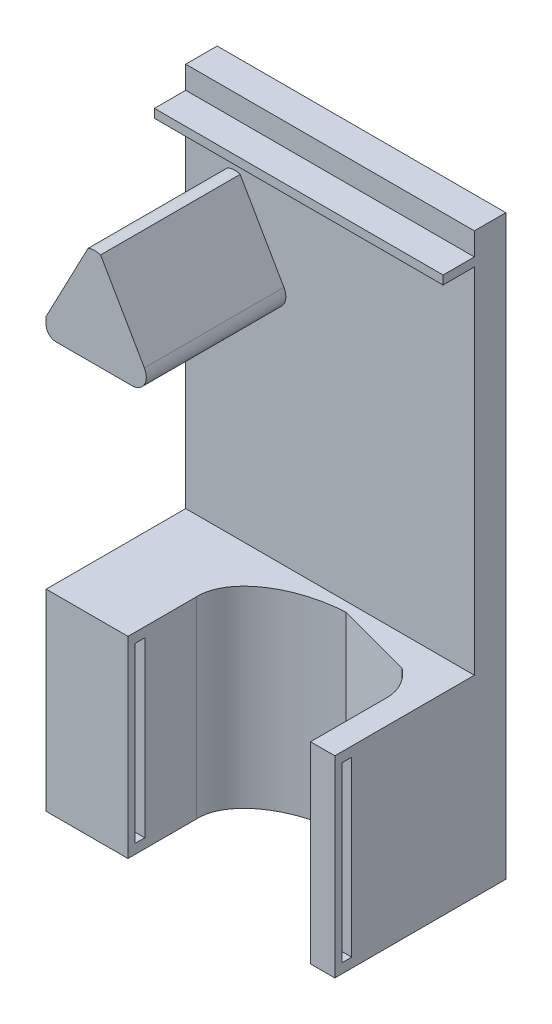
from build123d import *

# Parameters (mm, degrees)
SKETCH1_W           = 60
SKETCH1_H           = 120
BOSS_EXTRUDE1_DEPTH = 6.54
SKETCH17_W          = 60
SKETCH17_H          = 40
BOSS_EXTRUDE6_DEPTH = 29
CUT_EXTRUDE1_REACH  = 42
CUT_EXTRUDE2_REACH  = 37.54
SKETCH21_W          = 37.9445377
SKETCH21_H          = 40
SKETCH23_W          = 2
SKETCH23_H          = 36
CUT_EXTRUDE3_DEPTH  = 9
SKETCH24_W          = 2
SKETCH24_H          = 36
CUT_EXTRUDE4_DEPTH  = 9
BOSS_EXTRUDE8_DEPTH = 29
SKETCH36_W          = 60
SKETCH36_H          = 1.8
BOSS_EXTRUDE9_DEPTH = 6.5
FILLET1_R           = 3
FILLET2_R           = 2


with BuildPart() as part:
    # Sketch1 → Boss-Extrude1 (new body)
    with BuildSketch(Plane.XY):
        Rectangle(SKETCH1_W, SKETCH1_H)
    extrude(amount=BOSS_EXTRUDE1_DEPTH)

    # Sketch17 → Boss-Extrude6 (add)
    with BuildSketch(Plane.XY.offset(6.54)):
        with Locations((0, -40)):
            Rectangle(SKETCH17_W, SKETCH17_H)
    extrude(amount=BOSS_EXTRUDE6_DEPTH)

    # Sketch18 → Cut-Extrude1 (cut, up to next)
    with BuildSketch(Plane(origin=(0, -20, 0), x_dir=(1, 0, 0), z_dir=(0, 1, 0)), mode=Mode.PRIVATE) as cut_extrude1_sk1:
        with BuildLine():
            Line((5.334966353, -8.526396136), (21.291300905, -12.825812438))
            add(Edge.make_bspline(
                [(5.334966353, -8.526396136), (-17.854714365, -9.780670981), (-12.49786254, -23.648890313), (-7.141010715, -37.517109645), (13.926544327, -30.768916863), (34.994099369, -24.020724082), (21.291300905, -12.825812438)],
                knots=[1.570796327, 1.570796327, 1.570796327, 3.340987112, 3.340987112, 5.111177898, 5.111177898, 6.881368684, 6.881368684, 6.881368684], degree=2, weights=[1, 0.633215673, 1, 0.633215673, 1, 0.633215673, 1]))
        make_face()
    cut_extrude1_tool1 = extrude(cut_extrude1_sk1.sketch, amount=-CUT_EXTRUDE1_REACH, mode=Mode.PRIVATE) & part.part
    add(cut_extrude1_tool1.solids().sort_by_distance((5.792514, -20, 20.554542))[0], mode=Mode.SUBTRACT)

    # Sketch21 → Cut-Extrude2 (cut, up to next)
    with BuildSketch(Plane.XY.offset(35.54), mode=Mode.PRIVATE) as cut_extrude2_sk1:
        with Locations((5.97226885, -40)):
            Rectangle(SKETCH21_W, SKETCH21_H)
    cut_extrude2_tool1 = extrude(cut_extrude2_sk1.sketch, amount=-CUT_EXTRUDE2_REACH, mode=Mode.PRIVATE) & part.part
    add(cut_extrude2_tool1.solids().sort_by_distance((5.972269, -40, 35.54))[0], mode=Mode.SUBTRACT)

    # Sketch23 → Cut-Extrude3 (cut)
    with BuildSketch(Plane(origin=(-13, 0, 0), x_dir=(0, 0, -1), z_dir=(1, 0, 0))):
        with Locations((-33.04, -40)):
            Rectangle(SKETCH23_W, SKETCH23_H)
    extrude(amount=-CUT_EXTRUDE3_DEPTH, mode=Mode.SUBTRACT)

    # Sketch24 → Cut-Extrude4 (cut)
    with BuildSketch(Plane.ZY.offset(-24.9445377)):
        with Locations((33.04, -40)):
            Rectangle(SKETCH24_W, SKETCH24_H)
    extrude(amount=-CUT_EXTRUDE4_DEPTH, mode=Mode.SUBTRACT)

    # Sketch7 → Boss-Extrude8 (add)
    with BuildSketch(Plane.XY.offset(6.54)):
        with BuildLine():
            Line((-7, 25.533918981), (-18.684094898, 45.817285768))
            ThreePointArc((-18.684094898, 45.817285768), (-20, 46), (-21.294986864, 45.703352481))
            Line((-21.294986864, 45.703352481), (-30, 29.115374119))
            Line((-30, 29.115374119), (-30, 25.533918981))
            Line((-30, 25.533918981), (-7, 25.533918981))
        make_face()
    extrude(amount=BOSS_EXTRUDE8_DEPTH)

    # Sketch36 → Boss-Extrude9 (add)
    with BuildSketch(Plane.XY.offset(6.54)):
        with Locations((0, 54.4)):
            Rectangle(SKETCH36_W, SKETCH36_H)
    extrude(amount=BOSS_EXTRUDE9_DEPTH)

    # Fillet1
    fillet1_edges = [part.edges().sort_by_distance(p)[0] for p in [
        (-7, 25.533918981, 21.04),
    ]]
    fillet(fillet1_edges, radius=FILLET1_R)

    # Fillet2
    fillet2_edges = [part.edges().sort_by_distance(p)[0] for p in [
        (-30, 25.533918981, 21.04),
    ]]
    fillet(fillet2_edges, radius=FILLET2_R)


solid = part.part
